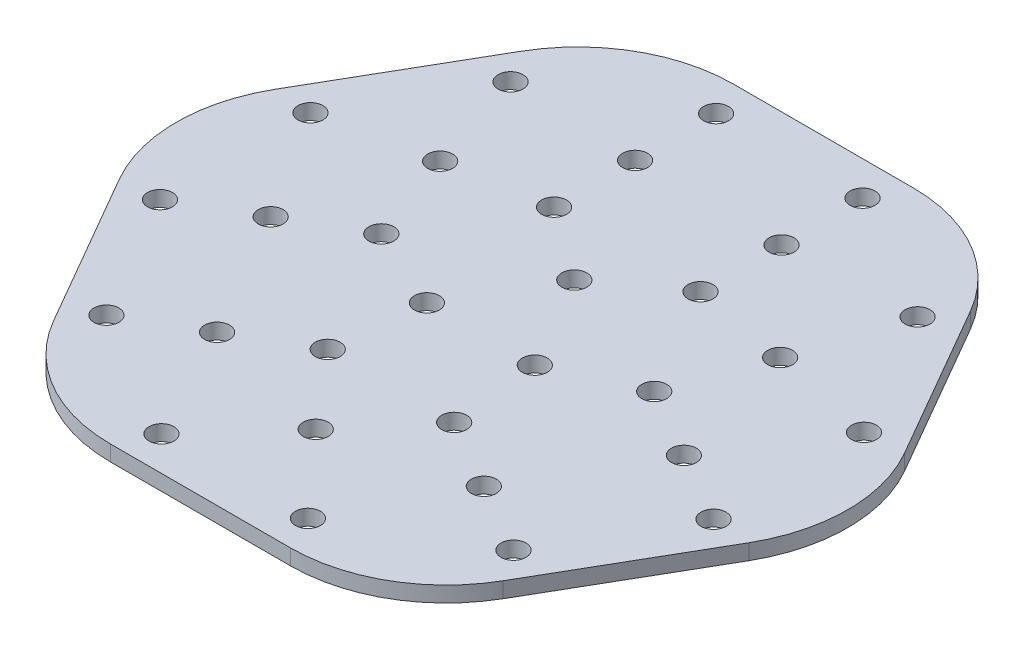
from build123d import *

# Parameters (mm, degrees)
EXTRUDE_1_DEPTH          = 5
SKETCH_2_R               = 4
CUT_EXTRUDE_1_DEPTH      = 153.834332967
PATTERN_CIRCULAR_1_COUNT = 3
SKETCH_3_R               = 4
CUT_EXTRUDE_2_DEPTH      = 153.834332967
PATTERN_CIRCULAR_2_COUNT = 3
SKETCH_4_R               = 4
CUT_EXTRUDE_3_DEPTH      = 153.834332967
PATTERN_CIRCULAR_3_COUNT = 3
FILLET_1_R               = 50


with BuildPart() as part:
    # 草图1 → 凸台-拉伸1 (new body)
    with BuildSketch(Plane(origin=(0, 0, 0), x_dir=(1, 0, 0), z_dir=(0, 1, 0))):
        Polygon((57.735026919, 100), (-57.735026919, 100), (-115.470053838, 0), (-57.735026919, -100), (57.735026919, -100), (115.470053838, 0), align=None)
    extrude(amount=EXTRUDE_1_DEPTH)

    # 草图2 → 切除-拉伸1 (cut, through all)
    with BuildSketch(Plane(origin=(0, 5, 0), x_dir=(1, 0, 0), z_dir=(0, 1, 0))):
        with Locations((-23.5, 37)):
            Circle(SKETCH_2_R)
        with Locations((23.5, 37)):
            Circle(SKETCH_2_R)
        with Locations((-23.5, 63)):
            Circle(SKETCH_2_R)
        with Locations((23.5, 63)):
            Circle(SKETCH_2_R)
        with Locations((-23.5, 89)):
            Circle(SKETCH_2_R)
        with Locations((23.5, 89)):
            Circle(SKETCH_2_R)
    cut_extrude_1 = extrude(amount=-CUT_EXTRUDE_1_DEPTH, mode=Mode.SUBTRACT)

    # 阵列(圆周)1: 切除-拉伸1 ×3 about axis
    pattern_circular_1_axis = Axis((0, -75.806700776, 0), (0, 1, 0))
    for i in range(1, PATTERN_CIRCULAR_1_COUNT):
        add(cut_extrude_1.rotate(pattern_circular_1_axis, i * 360 / PATTERN_CIRCULAR_1_COUNT), mode=Mode.SUBTRACT)

    # 草图3 → 切除-拉伸2 (cut, through all)
    with BuildSketch(Plane(origin=(0, 5, 0), x_dir=(1, 0, 0), z_dir=(0, 1, 0))):
        with Locations((65.326260937, 64.851596989)):
            Circle(SKETCH_3_R)
        with Locations((88.826260937, 24.148403011)):
            Circle(SKETCH_3_R)
        with Locations((54.559600438, 31.5)):
            Circle(SKETCH_3_R)
    cut_extrude_2 = extrude(amount=-CUT_EXTRUDE_2_DEPTH, mode=Mode.SUBTRACT)

    # 阵列(圆周)2: 切除-拉伸2 ×3 about axis
    pattern_circular_2_axis = Axis((0, -75.806700776, 0), (0, 1, 0))
    for i in range(1, PATTERN_CIRCULAR_2_COUNT):
        add(cut_extrude_2.rotate(pattern_circular_2_axis, i * 360 / PATTERN_CIRCULAR_2_COUNT), mode=Mode.SUBTRACT)

    # 草图4 → 切除-拉伸3 (cut, through all)
    with BuildSketch(Plane(origin=(0, 5, 0), x_dir=(1, 0, 0), z_dir=(0, 1, 0))):
        with Locations((0, 20)):
            Circle(SKETCH_4_R)
    cut_extrude_3 = extrude(amount=-CUT_EXTRUDE_3_DEPTH, mode=Mode.SUBTRACT)

    # 阵列(圆周)3: 切除-拉伸3 ×3 about axis
    pattern_circular_3_axis = Axis((0, -75.806700776, 0), (0, 1, 0))
    for i in range(1, PATTERN_CIRCULAR_3_COUNT):
        add(cut_extrude_3.rotate(pattern_circular_3_axis, i * 360 / PATTERN_CIRCULAR_3_COUNT), mode=Mode.SUBTRACT)

    # 圆角1
    fillet_1_edges = [part.edges().sort_by_distance(p)[0] for p in [
        (57.735026919, 2.5, -100),
        (-57.735026919, 2.5, -100),
        (-115.470053838, 2.5, 0),
        (-57.735026919, 2.5, 100),
        (57.735026919, 2.5, 100),
        (115.470053838, 2.5, 0),
    ]]
    fillet(fillet_1_edges, radius=FILLET_1_R)


solid = part.part
